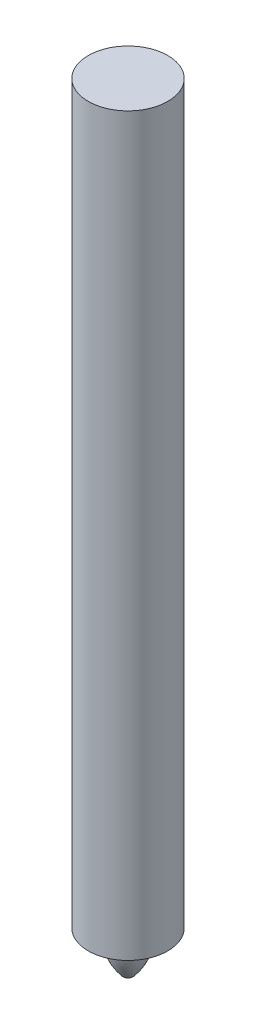
from build123d import *


with BuildPart() as part:
    # Sketch1 → Revolve1 (revolve)
    with BuildSketch(Plane.XY):
        with BuildLine():
            Line((0, 123.825), (6.35, 123.825))
            Line((6.35, 123.825), (6.35, 6.35))
            Line((6.35, 6.35), (3.175, 6.35))
            ThreePointArc((3.175, 6.35), (2.560112297, 2.959098514), (0.79375, 0))
            Line((0.79375, 0), (0, 0))
            Line((0, 0), (0, 123.825))
        make_face()
    revolve(axis=Axis((0, 0, 0), (0, 1, 0)))


solid = part.part
